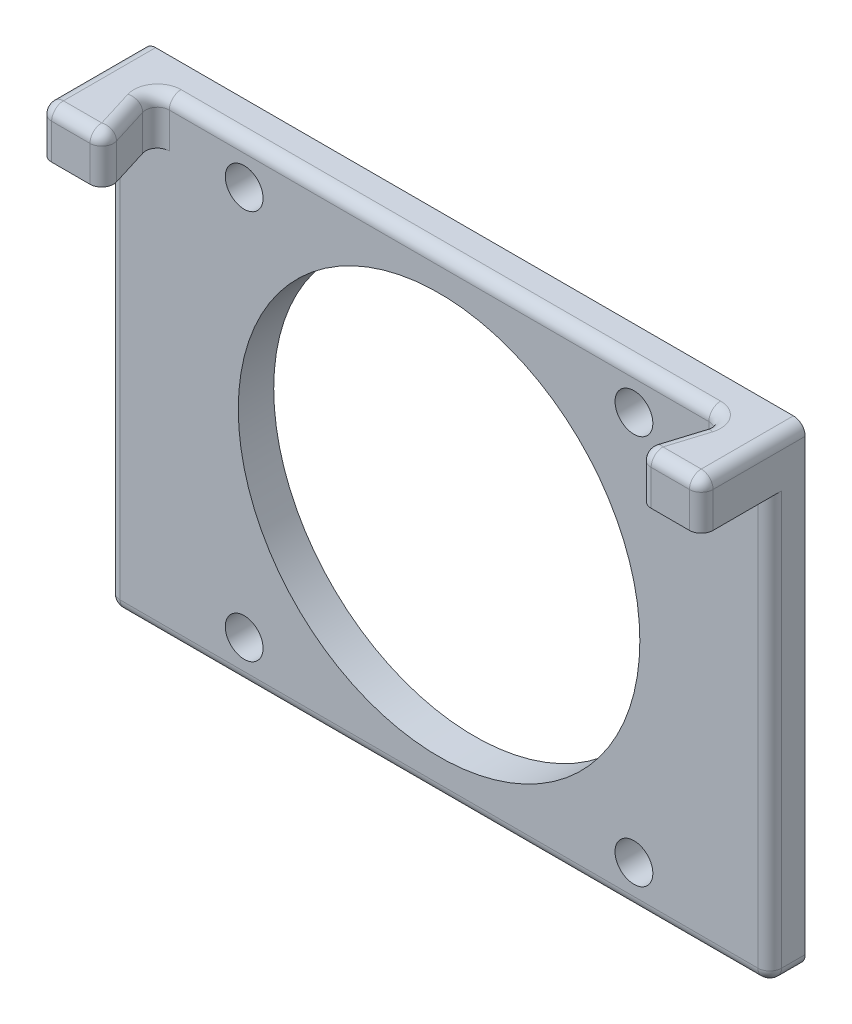
from build123d import *

# Parameters (mm, degrees)
ESQUISSE1_W             = 56
ESQUISSE1_H             = 40
BOSS_EXTRU_1_DEPTH      = 3
ESQUISSE2_W             = 3.8
ESQUISSE2_H             = 4
BOSS_EXTRU_2_DEPTH      = 5.8
BOSS_EXTRU_3_DEPTH      = 4
CONG_1_R                = 1
ESQUISSE4_R             = 1.6
ENL_V_MAT_EXTRU_1_DEPTH = 9.8
ESQUISSE5_R             = 17
ENL_V_MAT_EXTRU_2_DEPTH = 9.8


with BuildPart() as part:
    # Esquisse1 → Boss.-Extru.1 (new body)
    with BuildSketch(Plane.XY):
        Rectangle(ESQUISSE1_W, ESQUISSE1_H)
    extrude(amount=BOSS_EXTRU_1_DEPTH)

    # Esquisse2 → Boss.-Extru.2 (add)
    with BuildSketch(Plane.XY.offset(3)):
        with Locations((-26.1, 18)):
            Rectangle(ESQUISSE2_W, ESQUISSE2_H)
        with Locations((26.1, 18)):
            Rectangle(ESQUISSE2_W, ESQUISSE2_H)
    extrude(amount=BOSS_EXTRU_2_DEPTH)

    # Esquisse3 → Boss.-Extru.3 (add)
    with BuildSketch(Plane(origin=(0, 20, 0), x_dir=(1, 0, 0), z_dir=(0, 1, 0))):
        Polygon((-24.2, -3), (-22.4, -8.8), (-24.2, -8.8), align=None)
        Polygon((24.2, -3), (24.2, -8.8), (22.4, -8.8), align=None)
    extrude(amount=-BOSS_EXTRU_3_DEPTH)

    # Congé1
    cong_1_edges = [part.edges().sort_by_distance(p)[0] for p in [
        (23.3, 20, 5.9),
        (-23.3, 20, 5.9),
        (28, -20, 1.5),
        (-28, -20, 1.5),
        (-28, 20, 4.4),
        (28, 20, 4.4),
        (25.2, 20, 8.8),
        (-25.2, 20, 8.8),
        (0, 20, 3),
        (0, -20, 3),
        (28, -2, 3),
        (-28, -2, 3),
        (24.2, 18, 3),
        (22.4, 18, 8.8),
        (28, 18, 8.8),
        (-28, 18, 8.8),
        (-22.4, 18, 8.8),
        (-24.2, 18, 3),
    ]]
    fillet(cong_1_edges, radius=CONG_1_R)

    # Esquisse4 → Enlèv. mat.-Extru.1 (cut, through all)
    with BuildSketch(Plane(origin=(0, 0, 0), x_dir=(-1, 0, 0), z_dir=(0, 0, -1))):
        with Locations((-16.5, 16.5)):
            Circle(ESQUISSE4_R)
        with Locations((-16.5, -16.5)):
            Circle(ESQUISSE4_R)
        with Locations((16.5, 16.5)):
            Circle(ESQUISSE4_R)
        with Locations((16.5, -16.5)):
            Circle(ESQUISSE4_R)
    extrude(amount=-ENL_V_MAT_EXTRU_1_DEPTH, mode=Mode.SUBTRACT)

    # Esquisse5 → Enlèv. mat.-Extru.2 (cut, through all)
    with BuildSketch(Plane(origin=(0, 0, 0), x_dir=(-1, 0, 0), z_dir=(0, 0, -1))):
        Circle(ESQUISSE5_R)
    extrude(amount=-ENL_V_MAT_EXTRU_2_DEPTH, mode=Mode.SUBTRACT)


solid = part.part
